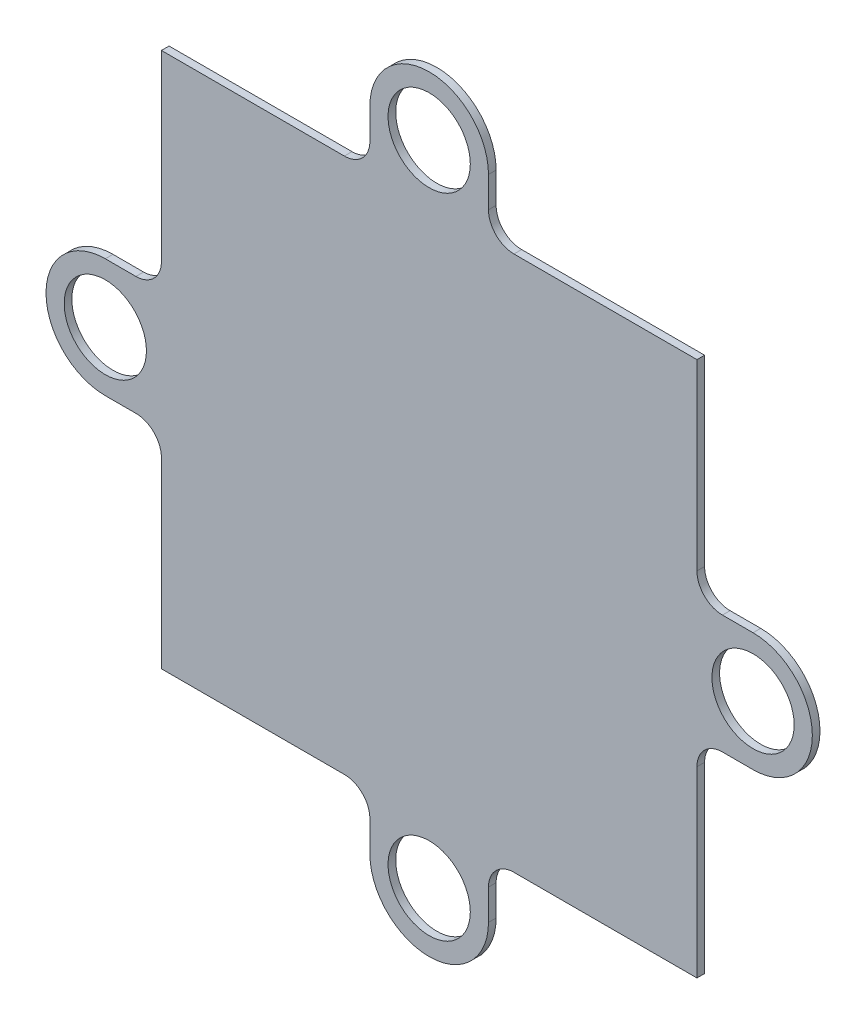
from build123d import *

# Parameters (mm, degrees)
SKETCH1_R           = 3.225
BOSS_EXTRUDE1_DEPTH = 0.6


with BuildPart() as part:
    # Sketch1 → Boss-Extrude1 (new body)
    with BuildSketch(Plane.XY):
        with BuildLine():
            ThreePointArc((4.65, 25.4), (0, 30.05), (-4.65, 25.4))
            Line((-4.65, 25.4), (-4.65, 23))
            ThreePointArc((-4.65, 23), (-5.235786438, 21.585786438), (-6.65, 21))
            Line((-6.65, 21), (-8.759132098, 21))
            Line((-8.759132098, 21), (-21, 21))
            Line((-21, 21), (-21, 7.133487824))
            Line((-21, 7.133487824), (-21, 6.65))
            ThreePointArc((-21, 6.65), (-21.585786438, 5.235786438), (-23, 4.65))
            Line((-23, 4.65), (-25.4, 4.65))
            ThreePointArc((-25.4, 4.65), (-30.05, 0), (-25.4, -4.65))
            Line((-25.4, -4.65), (-23, -4.65))
            ThreePointArc((-23, -4.65), (-21.585786438, -5.235786438), (-21, -6.65))
            Line((-21, -6.65), (-21, -8.759132098))
            Line((-21, -8.759132098), (-21, -21))
            Line((-21, -21), (-7.133487824, -21))
            Line((-7.133487824, -21), (-6.65, -21))
            ThreePointArc((-6.65, -21), (-5.235786438, -21.585786438), (-4.65, -23))
            Line((-4.65, -23), (-4.65, -25.4))
            ThreePointArc((-4.65, -25.4), (0, -30.05), (4.65, -25.4))
            Line((4.65, -25.4), (4.65, -23))
            ThreePointArc((4.65, -23), (5.235786438, -21.585786438), (6.65, -21))
            Line((6.65, -21), (8.759132098, -21))
            Line((8.759132098, -21), (21, -21))
            Line((21, -21), (21, -7.133487824))
            Line((21, -7.133487824), (21, -6.65))
            ThreePointArc((21, -6.65), (21.585786438, -5.235786438), (23, -4.65))
            Line((23, -4.65), (25.4, -4.65))
            ThreePointArc((25.4, -4.65), (30.05, 0), (25.4, 4.65))
            Line((25.4, 4.65), (23, 4.65))
            ThreePointArc((23, 4.65), (21.585786438, 5.235786438), (21, 6.65))
            Line((21, 6.65), (21, 8.759132098))
            Line((21, 8.759132098), (21, 21))
            Line((21, 21), (7.133487824, 21))
            Line((7.133487824, 21), (6.65, 21))
            ThreePointArc((6.65, 21), (5.235786438, 21.585786438), (4.65, 23))
            Line((4.65, 23), (4.65, 25.4))
        make_face()
        with Locations((0, -25.4)):
            Circle(SKETCH1_R, mode=Mode.SUBTRACT)
        with Locations((25.4, 0)):
            Circle(SKETCH1_R, mode=Mode.SUBTRACT)
        with Locations((-25.4, 0)):
            Circle(SKETCH1_R, mode=Mode.SUBTRACT)
        with Locations((0, 25.4)):
            Circle(SKETCH1_R, mode=Mode.SUBTRACT)
    extrude(amount=BOSS_EXTRUDE1_DEPTH)


solid = part.part
